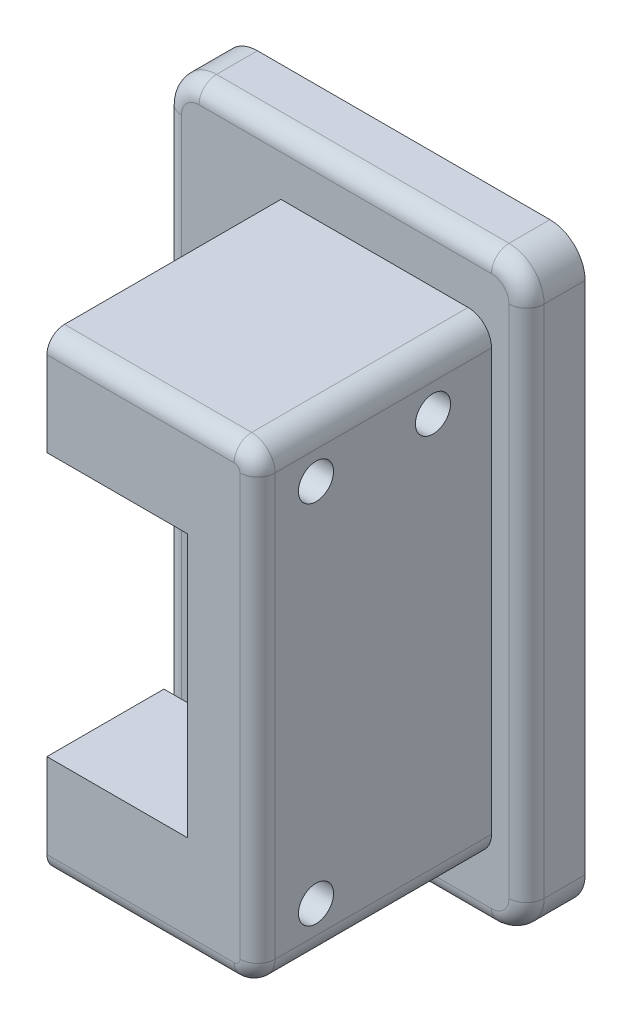
from build123d import *

# Parameters (mm, degrees)
BOSS_EXTRUDE1_DEPTH = 20
BOSS_EXTRUDE2_DEPTH = 5
FILLET1_R           = 2
SKETCH4_W           = 10
SKETCH4_H           = 10
CUT_EXTRUDE1_DEPTH  = 8.75
SKETCH5_R           = 1.5
CUT_EXTRUDE2_DEPTH  = 22
FILLET2_R           = 1.5


with BuildPart() as part:
    # Sketch1 → Boss-Extrude1 (new body)
    with BuildSketch(Plane.XY):
        Polygon((-130, -28), (-148, -28), (-148, -36.75), (-136, -36.75), (-136, -59.25), (-148, -59.25), (-148, -68), (-130, -68), align=None)
    extrude(amount=-BOSS_EXTRUDE1_DEPTH)

    # Sketch3 → Boss-Extrude2 (add)
    with BuildSketch(Plane(origin=(0, 0, -20), x_dir=(-1, 0, 0), z_dir=(0, 0, -1))):
        with BuildLine():
            Line((155, -73), (130, -73))
            ThreePointArc((130, -73), (127.878679656, -72.121320344), (127, -70))
            Line((127, -70), (127, -26))
            ThreePointArc((127, -26), (127.878679656, -23.878679656), (130, -23))
            Line((130, -23), (155, -23))
            ThreePointArc((155, -23), (157.121320344, -23.878679656), (158, -26))
            Line((158, -26), (158, -70))
            ThreePointArc((158, -70), (157.121320344, -72.121320344), (155, -73))
        make_face()
    extrude(amount=BOSS_EXTRUDE2_DEPTH)

    # Fillet1
    fillet1_edges = [part.edges().sort_by_distance(p)[0] for p in [
        (-130, -68, -10),
        (-130, -28, -10),
    ]]
    fillet(fillet1_edges, radius=FILLET1_R)

    # Sketch4 → Cut-Extrude1 (cut)
    with BuildSketch(Plane.XZ.offset(68)):
        with Locations((-143, -15)):
            Rectangle(SKETCH4_W, SKETCH4_H)
    extrude(amount=-CUT_EXTRUDE1_DEPTH, mode=Mode.SUBTRACT)

    # Sketch5 → Cut-Extrude2 (cut, through all)
    with BuildSketch(Plane.ZY.offset(148)):
        with Locations((-5, -32.375)):
            Circle(SKETCH5_R)
        with Locations((-15, -32.375)):
            Circle(SKETCH5_R)
        with Locations((-5, -63.625)):
            Circle(SKETCH5_R)
    extrude(amount=-CUT_EXTRUDE2_DEPTH, mode=Mode.SUBTRACT)

    # Fillet2
    fillet2_edges = [part.edges().sort_by_distance(p)[0] for p in [
        (-157.121320344, -72.121320344, -20),
        (-158, -48, -20),
        (-157.121320344, -23.878679656, -20),
        (-142.5, -23, -20),
        (-127.878679656, -23.878679656, -20),
        (-127, -48, -20),
        (-127.878679656, -72.121320344, -20),
        (-142.5, -73, -20),
        (-130, -48, 0),
        (-140, -28, 0),
        (-130.585786438, -67.414213562, 0),
        (-130.585786438, -28.585786438, 0),
        (-140, -68, 0),
    ]]
    fillet(fillet2_edges, radius=FILLET2_R)


solid = part.part
